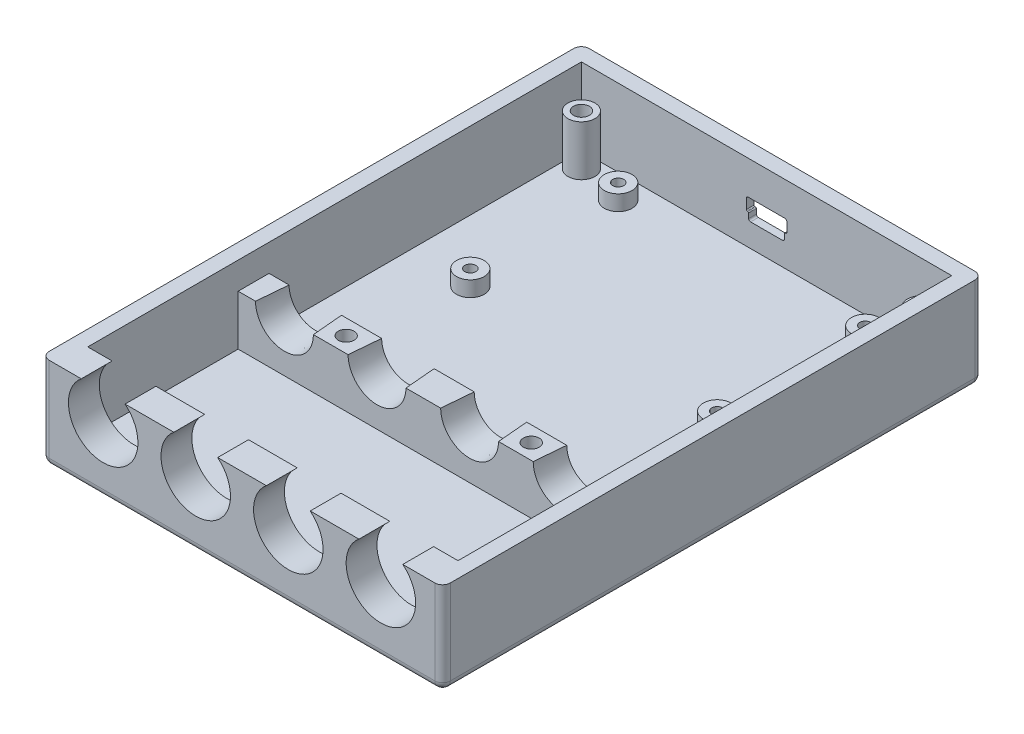
from build123d import *

# Parameters (mm, degrees)
SKETCH1_W                                       = 82.55
SKETCH1_H                                       = 111.125
BOSS_EXTRUDE1_DEPTH                             = 19.05
SKETCH14_W                                      = 76.2
SKETCH14_H                                      = 101.6
CUT_EXTRUDE3_DEPTH                              = 15.875
CUT_EXTRUDE4_REACH                              = 113.125
SKETCH11_R                                      = 7.1501
SKETCH17_R                                      = 2.778125
SKETCH17_W                                      = 76.2
SKETCH17_H                                      = 6.35
BOSS_EXTRUDE4_DEPTH                             = 10.3251
SKETCH18_R                                      = 5.953125
CUT_EXTRUDE5_DEPTH                              = 6.35
CUT_EXTRUDE5_TAPER                              = 5
CUT_EXTRUDE7_REACH                              = 113.125
FILLET6_R                                       = 1.5875
SKETCH19_R                                      = 2.8575
BOSS_EXTRUDE8_DEPTH                             = 3.175
CBORE_FOR_4_PAN_HEAD_MACHINE_SCREW3_D           = 3.2639
CBORE_FOR_4_PAN_HEAD_MACHINE_SCREW3_CBORE_D     = 6.35
CBORE_FOR_4_PAN_HEAD_MACHINE_SCREW3_CBORE_DEPTH = 2.032
F_4_40_TAPPED_HOLE1_D                           = 2.2606
F_4_40_TAPPED_HOLE1_DEPTH                       = 4.7752
F_4_40_TAPPED_HOLE1_TIP                         = 0.679152758
SKETCH39_W                                      = 17.4625
SKETCH39_H                                      = 14.2875
CUT_EXTRUDE8_DEPTH                              = 1.5875
FILLET7_R                                       = 0.79375
FILLET8_R                                       = 0.1984375
FILLET9_R                                       = 0.396875


with BuildPart() as part:
    # Sketch1 → Boss-Extrude1 (new body)
    with BuildSketch(Plane(origin=(0, 0, 0), x_dir=(1, 0, 0), z_dir=(0, 1, 0))):
        Rectangle(SKETCH1_W, SKETCH1_H)
    extrude(amount=BOSS_EXTRUDE1_DEPTH)

    # Sketch14 → Cut-Extrude3 (cut)
    with BuildSketch(Plane(origin=(0, 19.05, 0), x_dir=(-1, 0, 0), z_dir=(0, 1, 0))):
        with Locations((0, -1.5875)):
            Rectangle(SKETCH14_W, SKETCH14_H)
    extrude(amount=-CUT_EXTRUDE3_DEPTH, mode=Mode.SUBTRACT)

    # Sketch11 → Cut-Extrude4 (cut, up to next)
    with BuildSketch(Plane.XY.offset(55.5625), mode=Mode.PRIVATE) as cut_extrude4_sk1:
        with Locations((-28.575, 13.5001)):
            Circle(SKETCH11_R)
    cut_extrude4_tool1 = extrude(cut_extrude4_sk1.sketch, amount=-CUT_EXTRUDE4_REACH, mode=Mode.PRIVATE) & part.part
    add(cut_extrude4_tool1.solids().sort_by_distance((-28.575, 13.5001, 55.5625))[0], mode=Mode.SUBTRACT)
    # Sketch11 → Cut-Extrude4 (cut, up to next)
    with BuildSketch(Plane.XY.offset(55.5625), mode=Mode.PRIVATE) as cut_extrude4_sk2:
        with Locations((-9.525, 13.5001)):
            Circle(SKETCH11_R)
    cut_extrude4_tool2 = extrude(cut_extrude4_sk2.sketch, amount=-CUT_EXTRUDE4_REACH, mode=Mode.PRIVATE) & part.part
    add(cut_extrude4_tool2.solids().sort_by_distance((-9.525, 13.5001, 55.5625))[0], mode=Mode.SUBTRACT)
    # Sketch11 → Cut-Extrude4 (cut, up to next)
    with BuildSketch(Plane.XY.offset(55.5625), mode=Mode.PRIVATE) as cut_extrude4_sk3:
        with Locations((9.525, 13.5001)):
            Circle(SKETCH11_R)
    cut_extrude4_tool3 = extrude(cut_extrude4_sk3.sketch, amount=-CUT_EXTRUDE4_REACH, mode=Mode.PRIVATE) & part.part
    add(cut_extrude4_tool3.solids().sort_by_distance((9.525, 13.5001, 55.5625))[0], mode=Mode.SUBTRACT)
    # Sketch11 → Cut-Extrude4 (cut, up to next)
    with BuildSketch(Plane.XY.offset(55.5625), mode=Mode.PRIVATE) as cut_extrude4_sk4:
        with Locations((28.575, 13.5001)):
            Circle(SKETCH11_R)
    cut_extrude4_tool4 = extrude(cut_extrude4_sk4.sketch, amount=-CUT_EXTRUDE4_REACH, mode=Mode.PRIVATE) & part.part
    add(cut_extrude4_tool4.solids().sort_by_distance((28.575, 13.5001, 55.5625))[0], mode=Mode.SUBTRACT)

    # Sketch17 → Boss-Extrude4 (add)
    with BuildSketch(Plane(origin=(0, 3.175, 0), x_dir=(-1, 0, 0), z_dir=(0, 1, 0))):
        with Locations((34.925, -49.2125)):
            Circle(SKETCH17_R)
        with Locations((-34.925, -49.2125)):
            Circle(SKETCH17_R)
        with Locations((0, 15.08125)):
            Rectangle(SKETCH17_W, SKETCH17_H)
    extrude(amount=BOSS_EXTRUDE4_DEPTH)

    # Sketch18 → Cut-Extrude5 (cut)
    with BuildSketch(Plane.XY.offset(18.25625)):
        with Locations((-28.575, 13.5001)):
            Circle(SKETCH18_R)
        with Locations((-9.525, 13.5001)):
            Circle(SKETCH18_R)
        with Locations((9.525, 13.5001)):
            Circle(SKETCH18_R)
        with Locations((28.575, 13.5001)):
            Circle(SKETCH18_R)
    extrude(amount=-CUT_EXTRUDE5_DEPTH, taper=CUT_EXTRUDE5_TAPER, mode=Mode.SUBTRACT)

    # Sketch21 → Cut-Extrude7 (cut, up to next)
    with BuildSketch(Plane(origin=(0, 0, -55.5625), x_dir=(-1, 0, 0), z_dir=(0, 0, -1)), mode=Mode.PRIVATE) as cut_extrude7_sk1:
        Polygon((-3.683, 7.9375), (-3.683, 9.525), (-4.1671875, 9.525), (-4.1671875, 12.1046875), (4.1671875, 12.1046875), (4.1671875, 9.525), (3.683, 9.525), (3.683, 7.9375), align=None)
    cut_extrude7_tool1 = extrude(cut_extrude7_sk1.sketch, amount=-CUT_EXTRUDE7_REACH, mode=Mode.PRIVATE) & part.part
    add(cut_extrude7_tool1.solids().sort_by_distance((0, 10.08083, -55.5625))[0], mode=Mode.SUBTRACT)

    # Fillet6
    fillet6_edges = [part.edges().sort_by_distance(p)[0] for p in [
        (0, 0, 55.5625),
        (-41.275, 0, 0),
        (0, 0, -55.5625),
        (41.275, 0, 0),
        (41.275, 9.525, 55.5625),
        (-41.275, 9.525, 55.5625),
        (-41.275, 9.525, -55.5625),
        (41.275, 9.525, -55.5625),
    ]]
    fillet(fillet6_edges, radius=FILLET6_R)

    # Sketch19 → Boss-Extrude8 (add)
    with BuildSketch(Plane(origin=(0, 3.175, 0), x_dir=(-1, 0, 0), z_dir=(0, 1, 0))):
        with Locations((25.5143, -47.371)):
            Circle(SKETCH19_R)
        with Locations((-25.4, -47.3075)):
            Circle(SKETCH19_R)
        with Locations((25.4, -16.8275)):
            Circle(SKETCH19_R)
        with Locations((-25.4, -16.8275)):
            Circle(SKETCH19_R)
    extrude(amount=BOSS_EXTRUDE8_DEPTH)

    # CBORE for #4 Pan Head Machine Screw3 (through all)
    with Locations(Plane.XZ):
        with Locations((-19.05, 15.08125), (19.05, 15.08125), (-34.925, -49.2125), (34.925, -49.2125)):
            CounterBoreHole(CBORE_FOR_4_PAN_HEAD_MACHINE_SCREW3_D / 2, CBORE_FOR_4_PAN_HEAD_MACHINE_SCREW3_CBORE_D / 2, CBORE_FOR_4_PAN_HEAD_MACHINE_SCREW3_CBORE_DEPTH)

    # #4-40 Tapped Hole1
    with Locations(Plane(origin=(0, 6.35, 0), x_dir=(-1, 0, 0), z_dir=(0, 1, 0))):
        with Locations((25.5143, -47.371), (25.4, -16.8275), (-25.4, -16.8275), (-25.4, -47.3075)):
            Hole(F_4_40_TAPPED_HOLE1_D / 2, depth=F_4_40_TAPPED_HOLE1_DEPTH)
            with Locations((0, 0, -(F_4_40_TAPPED_HOLE1_DEPTH + F_4_40_TAPPED_HOLE1_TIP / 2))):  # 118° drill point
                Cone(0, F_4_40_TAPPED_HOLE1_D / 2, F_4_40_TAPPED_HOLE1_TIP, mode=Mode.SUBTRACT)

    # Sketch39 → Cut-Extrude8 (cut)
    with BuildSketch(Plane(origin=(0, 0, -55.5625), x_dir=(-1, 0, 0), z_dir=(0, 0, -1))):
        with Locations((0, 10.02109375)):
            Rectangle(SKETCH39_W, SKETCH39_H)
    extrude(amount=-CUT_EXTRUDE8_DEPTH, mode=Mode.SUBTRACT)

    # Fillet7
    fillet7_edges = [part.edges().sort_by_distance(p)[0] for p in [
        (-8.73125, 17.16484375, -54.76875),
        (-8.73125, 2.87734375, -54.76875),
        (8.73125, 2.87734375, -54.76875),
        (8.73125, 17.16484375, -54.76875),
    ]]
    fillet(fillet7_edges, radius=FILLET7_R)

    # Fillet8
    fillet8_edges = [part.edges().sort_by_distance(p)[0] for p in [
        (3.683, 9.525, -53.18125),
        (4.1671875, 9.525, -53.18125),
        (-4.1671875, 9.525, -53.18125),
        (-3.683, 9.525, -53.18125),
    ]]
    fillet(fillet8_edges, radius=FILLET8_R)

    # Fillet9
    fillet9_edges = [part.edges().sort_by_distance(p)[0] for p in [
        (-3.683, 7.9375, -53.18125),
        (3.683, 7.9375, -53.18125),
        (4.1671875, 12.1046875, -53.18125),
        (-4.1671875, 12.1046875, -53.18125),
    ]]
    fillet(fillet9_edges, radius=FILLET9_R)


solid = part.part
